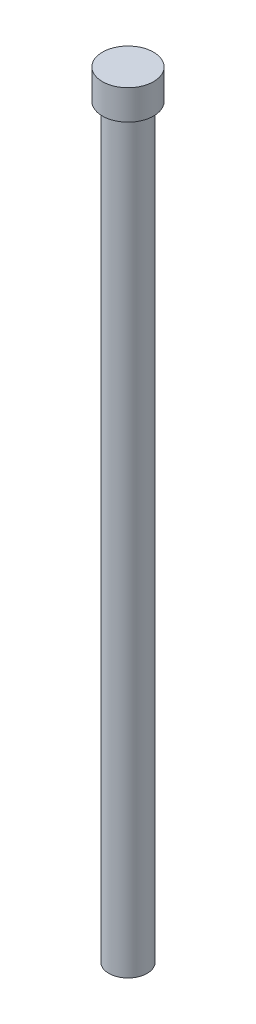
from build123d import *

# Parameters (mm, degrees)
SKETCH1_R             = 0.9
NAIL_SHAFT_BODY_DEPTH = 35
SKETCH2_R             = 1.2
NAIL_HEAD_DEPTH       = 1.4


with BuildPart() as part:
    # Sketch1 → nail_shaft_body (new body)
    with BuildSketch(Plane(origin=(0, 0, 0), x_dir=(1, 0, 0), z_dir=(0, 1, 0))):
        Circle(SKETCH1_R)
    extrude(amount=NAIL_SHAFT_BODY_DEPTH)

    # Sketch2 → nail_head (add)
    with BuildSketch(Plane(origin=(0, 35, 0), x_dir=(1, 0, 0), z_dir=(0, 1, 0))):
        Circle(SKETCH2_R)
    extrude(amount=NAIL_HEAD_DEPTH)


solid = part.part
